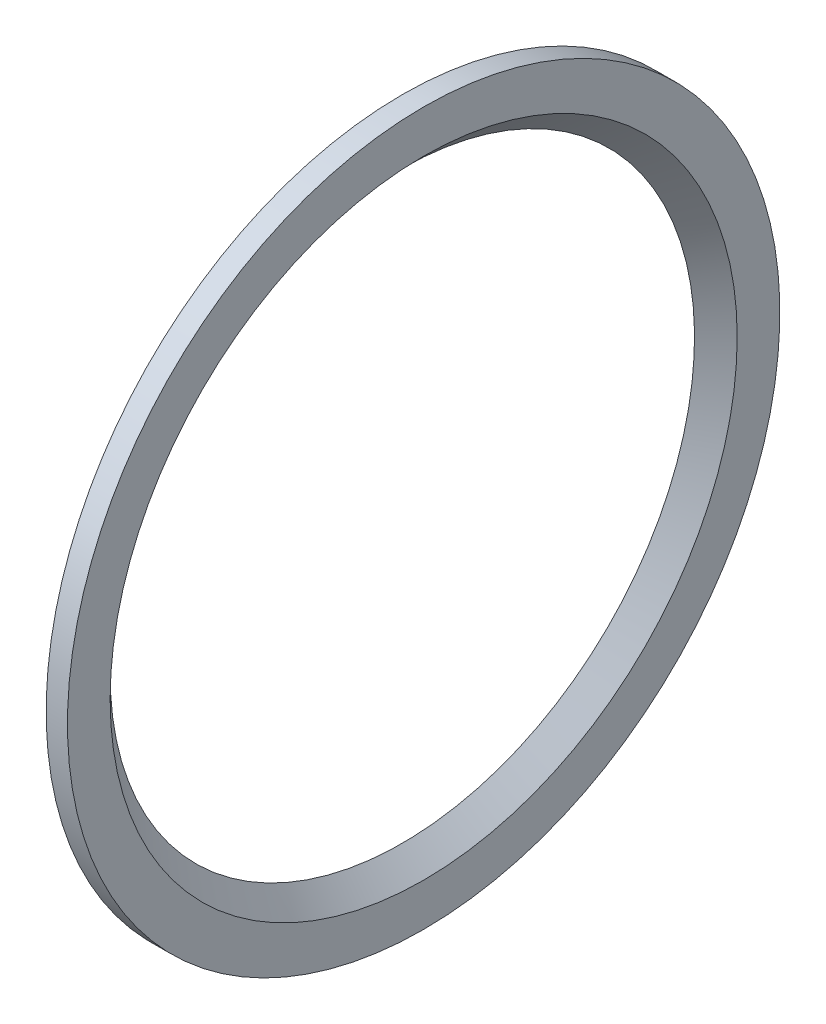
from build123d import *


with BuildPart() as part:
    # Skica1 → Rotovat1 (revolve)
    with BuildSketch(Plane.XY):
        Polygon((-115.05, -33.4), (-117.05, -33.4), (-117.05, -27.4), (-115.05, -29.4), align=None)
    revolve(axis=Axis((-67.482261058, 0, 0), (-1, 0, 0)))


solid = part.part
